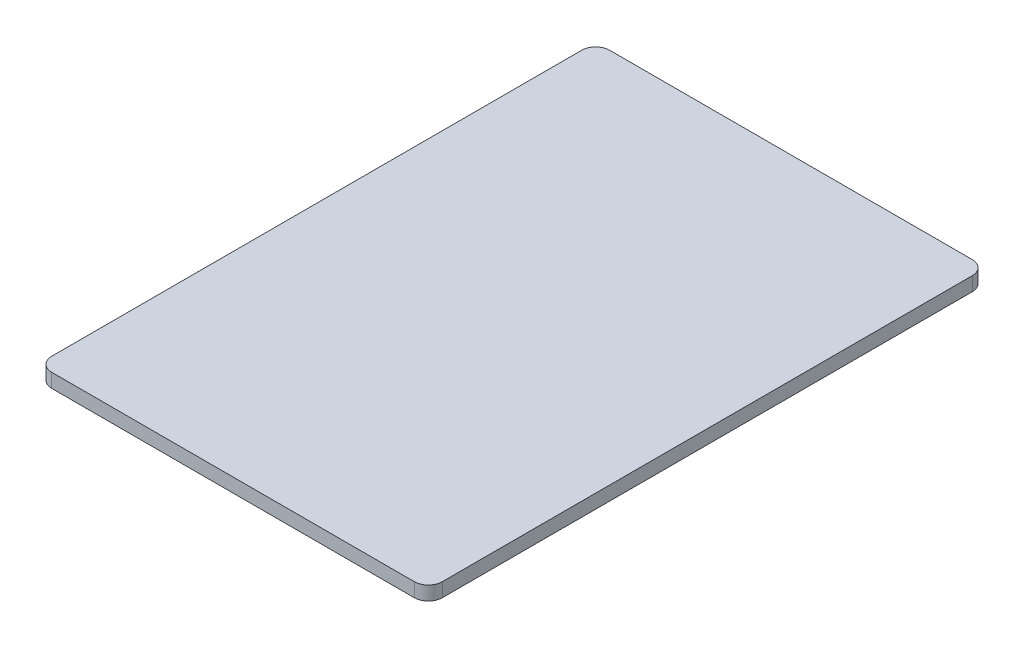
from build123d import *

# Parameters (mm, degrees)
BOSS_EXTRUDE1_DEPTH = 1.5875


with BuildPart() as part:
    # Sketch1 → Boss-Extrude1 (new body)
    with BuildSketch(Plane(origin=(0, 0, 0), x_dir=(1, 0, 0), z_dir=(0, 1, 0))):
        with BuildLine():
            Line((-22.225, -30.1625), (-22.225, 30.1625))
            ThreePointArc((-22.225, 30.1625), (-21.760032015, 31.285032015), (-20.6375, 31.75))
            Line((-20.6375, 31.75), (20.6375, 31.75))
            ThreePointArc((20.6375, 31.75), (21.760032015, 31.285032015), (22.225, 30.1625))
            Line((22.225, 30.1625), (22.225, -30.1625))
            ThreePointArc((22.225, -30.1625), (21.760032015, -31.285032015), (20.6375, -31.75))
            Line((20.6375, -31.75), (-20.6375, -31.75))
            ThreePointArc((-20.6375, -31.75), (-21.760032015, -31.285032015), (-22.225, -30.1625))
        make_face()
    extrude(amount=BOSS_EXTRUDE1_DEPTH)


solid = part.part
